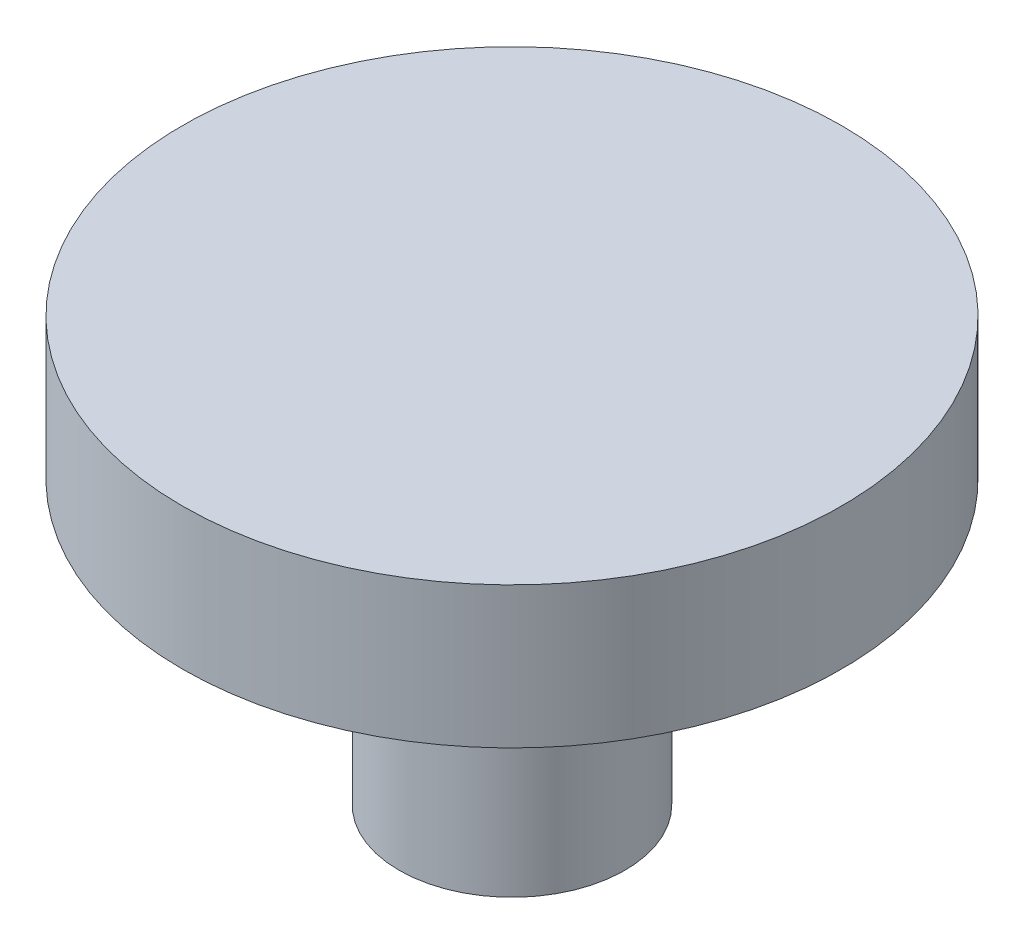
from build123d import *

# Parameters (mm, degrees)
CROQUIS1_R              = 2.4
SALIENTE_EXTRUIR1_DEPTH = 3
CROQUIS2_R              = 7
SALIENTE_EXTRUIR2_DEPTH = 3


with BuildPart() as part:
    # Croquis1 → Saliente-Extruir1 (new body, symmetric)
    with BuildSketch(Plane(origin=(0, 0, 0), x_dir=(1, 0, 0), z_dir=(0, 1, 0))):
        Circle(CROQUIS1_R)
    extrude(amount=SALIENTE_EXTRUIR1_DEPTH, both=True)

    # Croquis2 → Saliente-Extruir2 (add)
    with BuildSketch(Plane(origin=(0, 3, 0), x_dir=(1, 0, 0), z_dir=(0, 1, 0))):
        Circle(CROQUIS2_R)
    extrude(amount=SALIENTE_EXTRUIR2_DEPTH)


solid = part.part
